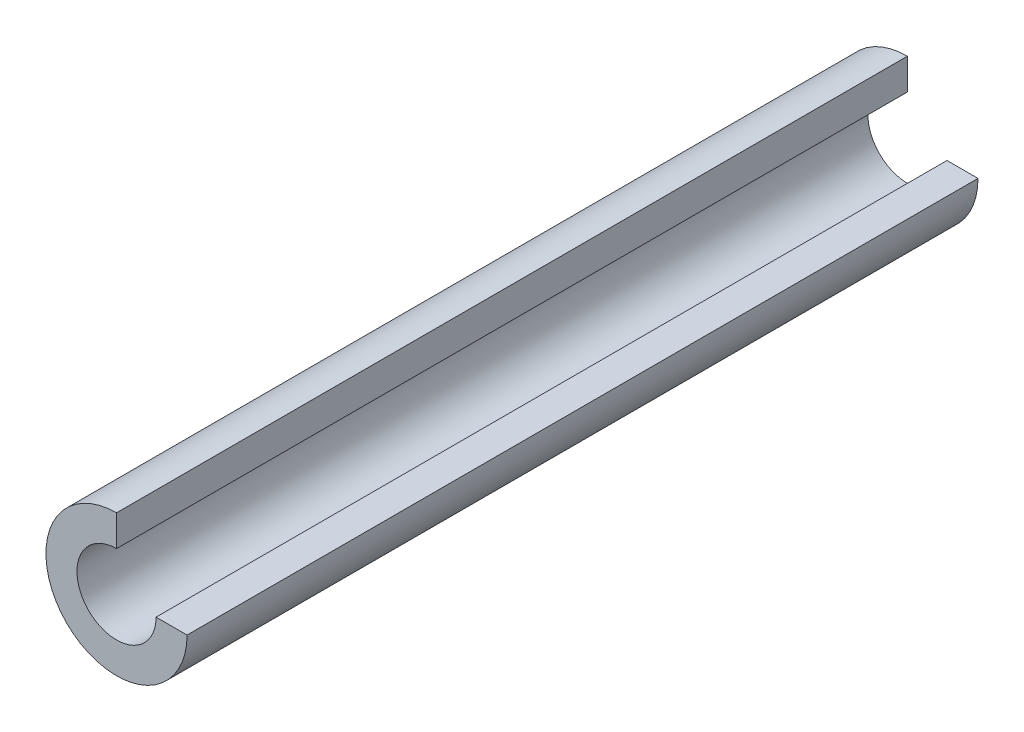
from build123d import *

# Parameters (mm, degrees)
BOSS_EXTRUDE1_DEPTH = 40
MOVE_FACE1_BY       = 11


with BuildPart() as part:
    # Sketch1 → Boss-Extrude1 (new body)
    with BuildSketch(Plane.XY):
        with BuildLine():
            Line((0, 2.55), (0, 4.55))
            ThreePointArc((0, 4.55), (-3.217335854, -3.217335854), (4.55, 0))
            Line((4.55, 0), (2.55, 0))
            ThreePointArc((2.55, 0), (-1.803122292, -1.803122292), (0, 2.55))
        make_face()
    extrude(amount=BOSS_EXTRUDE1_DEPTH)

    # Move Face1: a face moved outward by 11.0
    extrude(part.faces().sort_by_distance((0, -3.64, 40))[0], amount=MOVE_FACE1_BY, dir=(0, 0, 1))


solid = part.part
